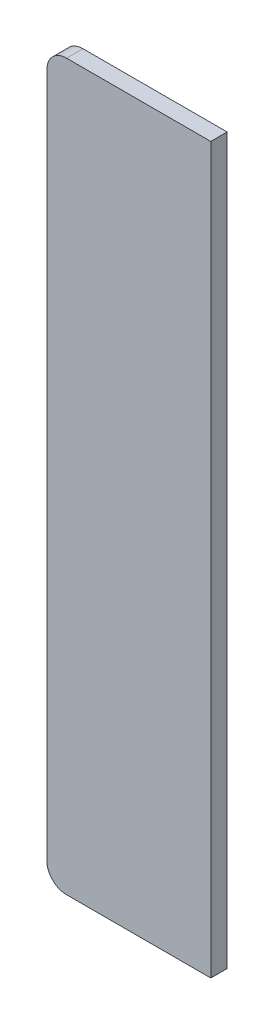
from build123d import *

# Parameters (mm, degrees)
SKETCH1_W           = 250
SKETCH1_H           = 1105
BOSS_EXTRUDE1_DEPTH = 25
FILLET1_R           = 30
FILLET2_R           = 30


with BuildPart() as part:
    # Sketch1 → Boss-Extrude1 (new body)
    with BuildSketch(Plane.XY):
        with Locations((125, 552.5)):
            Rectangle(SKETCH1_W, SKETCH1_H)
    extrude(amount=BOSS_EXTRUDE1_DEPTH)

    # Fillet1
    fillet1_edges = [part.edges().sort_by_distance(p)[0] for p in [
        (0, 1105, 12.5),
    ]]
    fillet(fillet1_edges, radius=FILLET1_R)

    # Fillet2
    fillet2_edges = [part.edges().sort_by_distance(p)[0] for p in [
        (0, 0, 12.5),
    ]]
    fillet(fillet2_edges, radius=FILLET2_R)


solid = part.part
